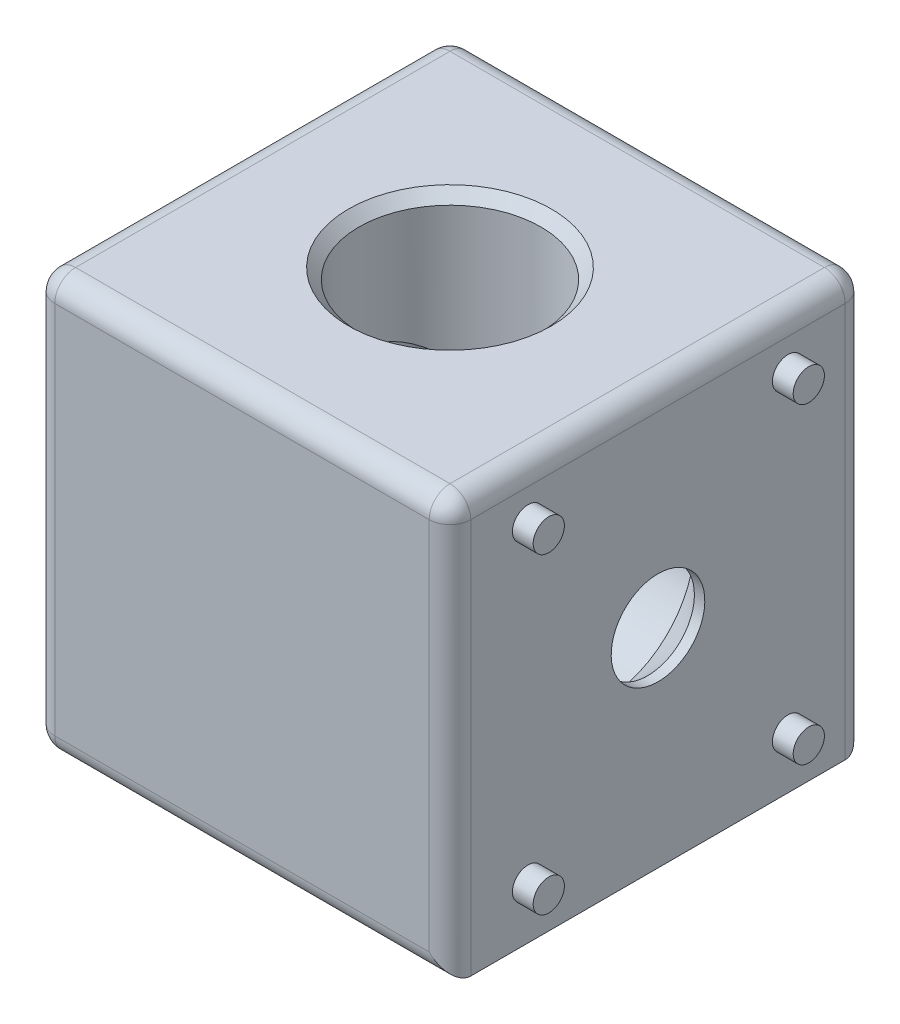
from build123d import *

# Parameters (mm, degrees)
SKETCH_1_W      = 40
SKETCH_1_H      = 40
EXTRUDE_1_DEPTH = 20
SKETCH_5_R      = 1.5
EXTRUDE_2_DEPTH = 2
FILLET_1_R      = 2


with BuildPart() as part:
    # Эскиз1 → Бобышка-Вытянуть1 (new body, symmetric)
    with BuildSketch(Plane(origin=(0, 0, 0), x_dir=(1, 0, 0), z_dir=(0, 1, 0))):
        Rectangle(SKETCH_1_W, SKETCH_1_H)
    extrude(amount=EXTRUDE_1_DEPTH, both=True)

    # Эскиз4 → Вырез-Повернуть1 (revolve, cut)
    with BuildSketch(Plane.XY):
        Polygon((-4.5, -20), (-4.5, -19), (-8.75, -14.75), (-8.75, 19), (-9.75, 20), (0, 20), (0, -20), align=None)
    cut_revolve_1 = revolve(axis=Axis((0, 20, 0), (0, -1, 0)), mode=Mode.SUBTRACT)

    # Эскиз5 → Бобышка-Вытянуть2 (add)
    with BuildSketch(Plane.XZ.offset(20)):
        with Locations(Location((-15, 12.5, 0), (0, 0, 270))):  # turned: the seam where the file's is
            Circle(SKETCH_5_R)
        with Locations(Location((-15, -12.5, 0), (0, 0, 270))):  # turned: the seam where the file's is
            Circle(SKETCH_5_R)
        with Locations(Location((15, -12.5, 0), (0, 0, 270))):  # turned: the seam where the file's is
            Circle(SKETCH_5_R)
        with Locations(Location((15, 12.5, 0), (0, 0, 270))):  # turned: the seam where the file's is
            Circle(SKETCH_5_R)
    extrude_2 = extrude(amount=EXTRUDE_2_DEPTH)

    # Зеркальное отражение1: Вырез-Повернуть1, Бобышка-Вытянуть2 across plane
    add(cut_revolve_1.mirror(Plane(origin=(0, 0, 0), x_dir=(0, 0, 1), z_dir=(0.707106781, 0.707106781, 0))), mode=Mode.SUBTRACT)
    add(extrude_2.mirror(Plane(origin=(0, 0, 0), x_dir=(0, 0, 1), z_dir=(0.707106781, 0.707106781, 0))))

    # Скругление1
    fillet_1_edges = [part.edges().sort_by_distance(p)[0] for p in [
        (-20, 20, 0),
        (0, 20, 20),
        (20, 20, 0),
        (0, -20, 20),
        (-20, -20, 0),
        (0, -20, -20),
        (20, 0, 20),
        (-20, 0, 20),
        (-20, 0, -20),
        (20, 0, -20),
        (0, 20, -20),
    ]]
    fillet(fillet_1_edges, radius=FILLET_1_R)


solid = part.part
